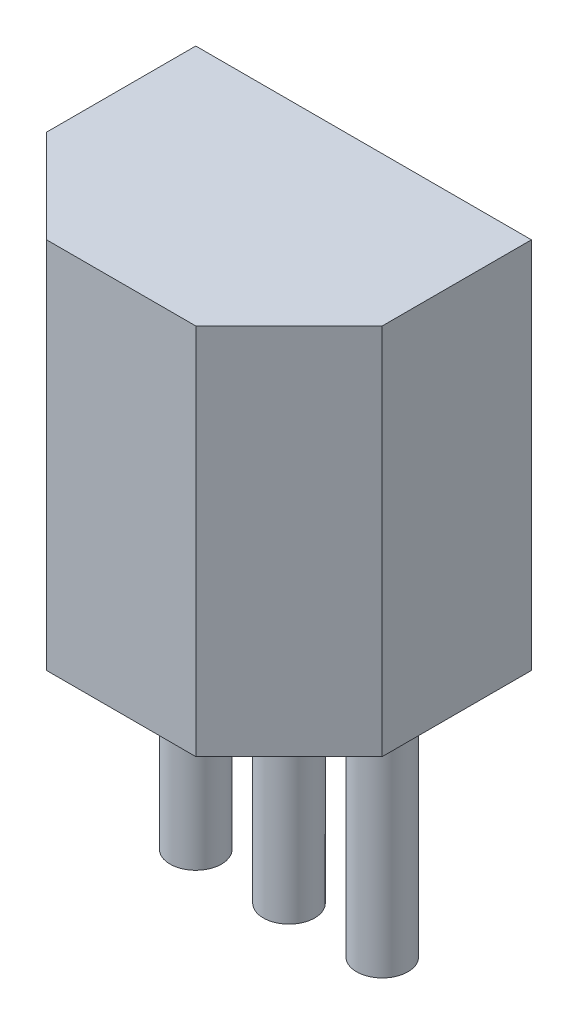
from build123d import *

# Parameters (mm, degrees)
BOSS_EXTRUDE1_DEPTH = 5.08
SKETCH2_R           = 0.35
BOSS_EXTRUDE2_DEPTH = 3.38


with BuildPart() as part:
    # Sketch1 → Boss-Extrude1 (new body)
    with BuildSketch(Plane(origin=(0, 0, 0), x_dir=(1, 0, 0), z_dir=(0, 1, 0))):
        Polygon((-1.016, -1.016), (0.254, -2.286), (2.286, -2.286), (3.556, -1.016), (3.556, 1.016), (-1.016, 1.016), align=None)
    extrude(amount=BOSS_EXTRUDE1_DEPTH)

    # Sketch2 → Boss-Extrude2 (add)
    with BuildSketch(Plane.XZ):
        Circle(SKETCH2_R)
        with Locations((1.27, 0)):
            Circle(SKETCH2_R)
        with Locations((2.54, 0)):
            Circle(SKETCH2_R)
    extrude(amount=BOSS_EXTRUDE2_DEPTH)


solid = part.part
